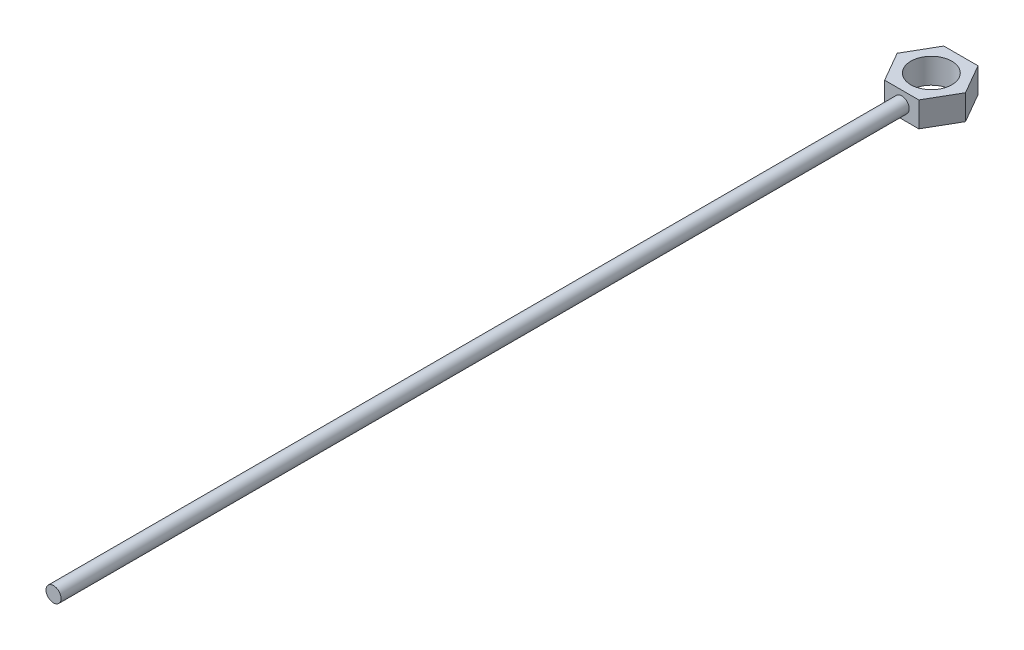
from build123d import *

# Parameters (mm, degrees)
CROQUIS1_R                   = 3.97256
SALIENTE_EXTRUIR2_DEPTH      = 5.08
CROQUIS2_R                   = 1.524
SALIENTE_EXTRUIR4_DEPTH      = 177.8
SALIENTE_EXTRUIR4_DEPTH_BACK = 2.54
CROQUIS3_R                   = 4.149655304
CORTAR_EXTRUIR1_DEPTH        = 20.32
CORTAR_EXTRUIR1_DEPTH_BACK   = 21.336


with BuildPart() as part:
    # Croquis1 → Saliente-Extruir2 (new body)
    with BuildSketch(Plane(origin=(0, 0, 0), x_dir=(1, 0, 0), z_dir=(0, 1, 0))):
        Polygon((6.921319842, 0), (3.460659921, 5.994038811), (-3.460659921, 5.994038811), (-6.921319842, 0), (-3.460659921, -5.994038811), (3.460659921, -5.994038811), align=None)
        Circle(CROQUIS1_R, mode=Mode.SUBTRACT)
    extrude(amount=SALIENTE_EXTRUIR2_DEPTH)

    # Croquis2 → Saliente-Extruir4 (add, two sides)
    with BuildSketch(Plane.XY) as saliente_extruir4_sk:
        with Locations((0, 2.54)):
            Circle(CROQUIS2_R)
    extrude(amount=SALIENTE_EXTRUIR4_DEPTH)
    extrude(saliente_extruir4_sk.sketch, amount=-SALIENTE_EXTRUIR4_DEPTH_BACK)

    # Croquis3 → Cortar-Extruir1 (cut, two sides)
    with BuildSketch(Plane(origin=(0, 0, 0), x_dir=(1, 0, 0), z_dir=(0, 1, 0))) as cortar_extruir1_sk:
        Circle(CROQUIS3_R)
    extrude(amount=CORTAR_EXTRUIR1_DEPTH, mode=Mode.SUBTRACT)
    extrude(cortar_extruir1_sk.sketch, amount=-CORTAR_EXTRUIR1_DEPTH_BACK, mode=Mode.SUBTRACT)


solid = part.part
